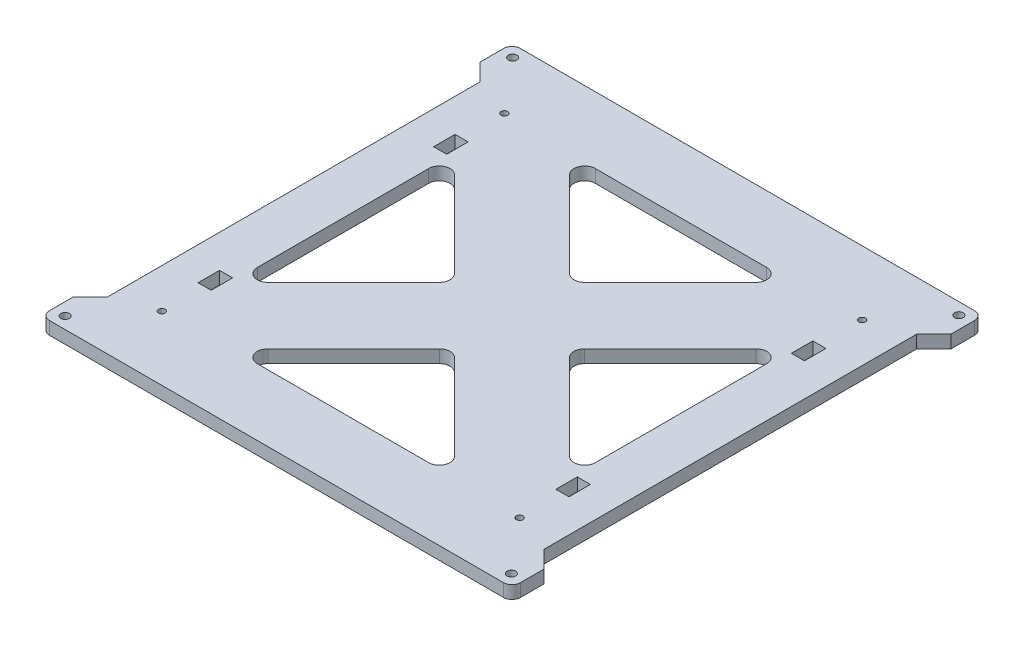
from build123d import *

# Parameters (mm, degrees)
SKETCH_1_R      = 2
SKETCH_1_R_2    = 1.55
SKETCH_1_W      = 6.1
SKETCH_1_H      = 10
EXTRUDE_1_DEPTH = 6


with BuildPart() as part:
    # Эскиз1 → Бобышка-Вытянуть1 (new body)
    with BuildSketch(Plane(origin=(0, 0, 0), x_dir=(1, 0, 0), z_dir=(0, 1, 0))):
        with BuildLine():
            Line((-121.241078921, -80.805954046), (-129.241078921, -88.805954046))
            Line((-129.241078921, -88.805954046), (-129.241078921, -99.805954046))
            ThreePointArc((-129.241078921, -99.805954046), (-128.069506046, -102.634381171), (-125.241078921, -103.805954046))
            Line((-125.241078921, -103.805954046), (86.758921079, -103.805954046))
            ThreePointArc((86.758921079, -103.805954046), (89.587348204, -102.634381171), (90.758921079, -99.805954046))
            Line((90.758921079, -99.805954046), (90.758921079, -88.805954046))
            Line((90.758921079, -88.805954046), (82.758921079, -80.805954046))
            Line((82.758921079, -80.805954046), (82.758921079, 93.194045954))
            Line((82.758921079, 93.194045954), (90.758921079, 101.194045954))
            Line((90.758921079, 101.194045954), (90.758921079, 112.194045954))
            ThreePointArc((90.758921079, 112.194045954), (89.587348204, 115.022473079), (86.758921079, 116.194045954))
            Line((86.758921079, 116.194045954), (-125.241078921, 116.194045954))
            ThreePointArc((-125.241078921, 116.194045954), (-128.069506046, 115.022473079), (-129.241078921, 112.194045954))
            Line((-129.241078921, 112.194045954), (-129.241078921, 101.194045954))
            Line((-129.241078921, 101.194045954), (-121.241078921, 93.194045954))
            Line((-121.241078921, 93.194045954), (-121.241078921, -80.805954046))
        make_face()
        with Locations((-123.441078921, -98.305954046)):
            Circle(SKETCH_1_R, mode=Mode.SUBTRACT)
        with Locations((84.958921079, -98.305954046)):
            Circle(SKETCH_1_R, mode=Mode.SUBTRACT)
        with Locations((-123.441078921, 110.694045954)):
            Circle(SKETCH_1_R, mode=Mode.SUBTRACT)
        with Locations((84.958921079, 110.694045954)):
            Circle(SKETCH_1_R, mode=Mode.SUBTRACT)
        with Locations((64.308921079, 86.194045954)):
            Circle(SKETCH_1_R_2, mode=Mode.SUBTRACT)
        with Locations((64.308921079, -73.805954046)):
            Circle(SKETCH_1_R_2, mode=Mode.SUBTRACT)
        with Locations((-102.791078921, -73.805954046)):
            Circle(SKETCH_1_R_2, mode=Mode.SUBTRACT)
        with Locations((-102.791078921, 86.194045954)):
            Circle(SKETCH_1_R_2, mode=Mode.SUBTRACT)
        with Locations((-102.791078921, 61.194045954)):
            Rectangle(SKETCH_1_W, SKETCH_1_H, mode=Mode.SUBTRACT)
        with Locations((64.308921079, -48.805954046)):
            Rectangle(SKETCH_1_W, SKETCH_1_H, mode=Mode.SUBTRACT)
        with BuildLine():
            Line((-59.241078921, -72.747079543), (20.758921079, -72.747079543))
            ThreePointArc((20.758921079, -72.747079543), (25.378318741, -69.660496705), (24.294454985, -64.211545637))
            Line((24.294454985, -64.211545637), (-15.705545015, -24.211545637))
            ThreePointArc((-15.705545015, -24.211545637), (-19.241078921, -22.747079543), (-22.776612827, -24.211545637))
            Line((-22.776612827, -24.211545637), (-62.776612827, -64.211545637))
            ThreePointArc((-62.776612827, -64.211545637), (-63.860476584, -69.660496705), (-59.241078921, -72.747079543))
        make_face(mode=Mode.SUBTRACT)
        with Locations((64.308921079, 61.194045954)):
            Rectangle(SKETCH_1_W, SKETCH_1_H, mode=Mode.SUBTRACT)
        with BuildLine():
            Line((20.758921079, 85.135171451), (-59.241078921, 85.135171451))
            ThreePointArc((-59.241078921, 85.135171451), (-63.860476584, 82.048588613), (-62.776612827, 76.599637545))
            Line((-62.776612827, 76.599637545), (-22.776612827, 36.599637545))
            ThreePointArc((-22.776612827, 36.599637545), (-19.241078921, 35.135171451), (-15.705545015, 36.599637545))
            Line((-15.705545015, 36.599637545), (24.294454985, 76.599637545))
            ThreePointArc((24.294454985, 76.599637545), (25.378318741, 82.048588613), (20.758921079, 85.135171451))
        make_face(mode=Mode.SUBTRACT)
        with BuildLine():
            Line((59.700046576, -33.805954046), (59.700046576, 46.194045954))
            ThreePointArc((59.700046576, 46.194045954), (56.613463738, 50.813443617), (51.16451267, 49.72957986))
            Line((51.16451267, 49.72957986), (11.16451267, 9.72957986))
            ThreePointArc((11.16451267, 9.72957986), (9.700046576, 6.194045954), (11.16451267, 2.658512048))
            Line((11.16451267, 2.658512048), (51.16451267, -37.341487952))
            ThreePointArc((51.16451267, -37.341487952), (56.613463738, -38.425351709), (59.700046576, -33.805954046))
        make_face(mode=Mode.SUBTRACT)
        with BuildLine():
            Line((-98.182204418, 46.194045954), (-98.182204418, -33.805954046))
            ThreePointArc((-98.182204418, -33.805954046), (-95.09562158, -38.425351709), (-89.646670512, -37.341487952))
            Line((-89.646670512, -37.341487952), (-49.646670512, 2.658512048))
            ThreePointArc((-49.646670512, 2.658512048), (-48.182204418, 6.194045954), (-49.646670512, 9.72957986))
            Line((-49.646670512, 9.72957986), (-89.646670512, 49.72957986))
            ThreePointArc((-89.646670512, 49.72957986), (-95.09562158, 50.813443617), (-98.182204418, 46.194045954))
        make_face(mode=Mode.SUBTRACT)
        with Locations((-102.791078921, -48.805954046)):
            Rectangle(SKETCH_1_W, SKETCH_1_H, mode=Mode.SUBTRACT)
    extrude(amount=EXTRUDE_1_DEPTH)


solid = part.part
